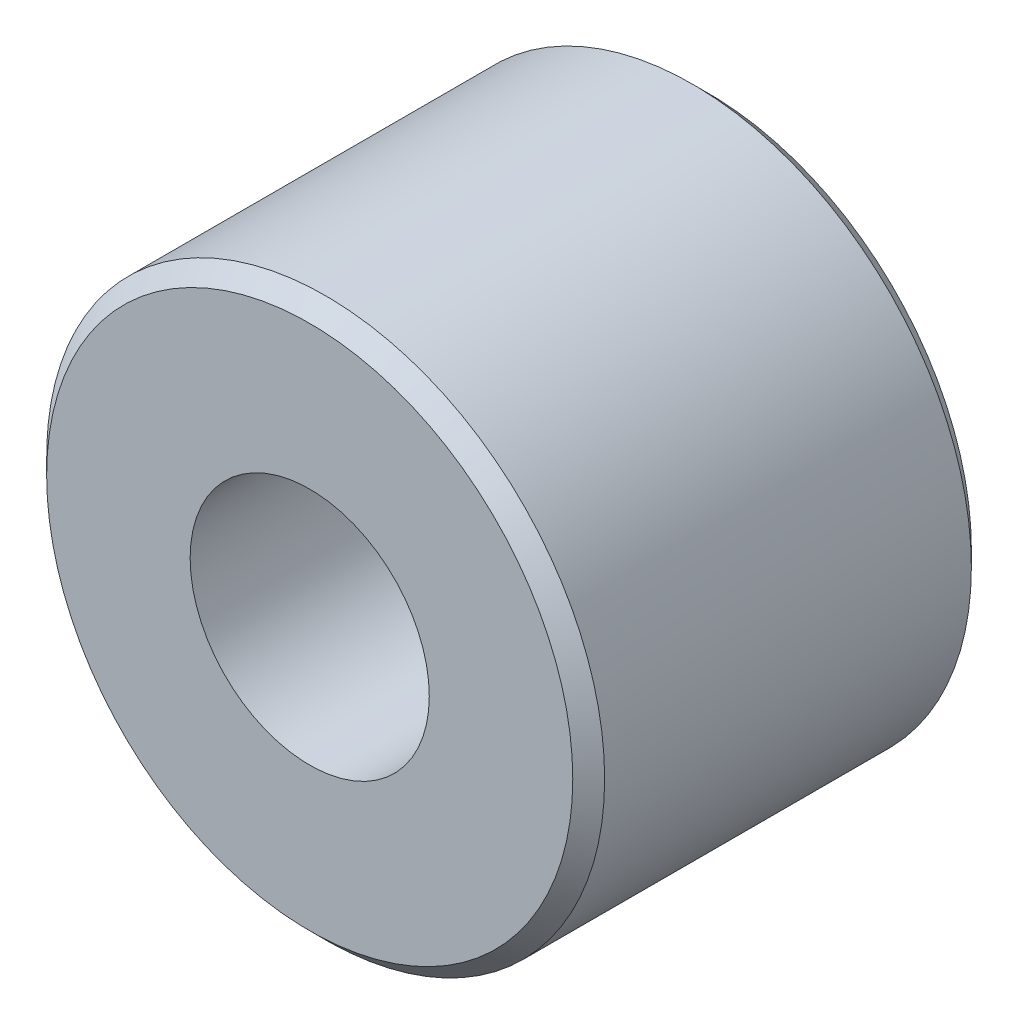
from build123d import *

# Parameters (mm, degrees)
ESQUISSE1_R          = 3.5
ESQUISSE1_R_2        = 1.5
BASE_EXTRUSION_DEPTH = 5
CHANFREIN1_SIZE      = 0.2


with BuildPart() as part:
    # Esquisse1 → Base-Extrusion (new body)
    with BuildSketch(Plane.XY):
        Circle(ESQUISSE1_R)
        Circle(ESQUISSE1_R_2, mode=Mode.SUBTRACT)
    extrude(amount=BASE_EXTRUSION_DEPTH)

    # Chanfrein1
    chanfrein1_edges = [part.edges().sort_by_distance(p)[0] for p in [
        (-3.5, 0, 0),
        (-3.5, 0, 5),
    ]]
    chamfer(chanfrein1_edges, length=CHANFREIN1_SIZE)


solid = part.part
